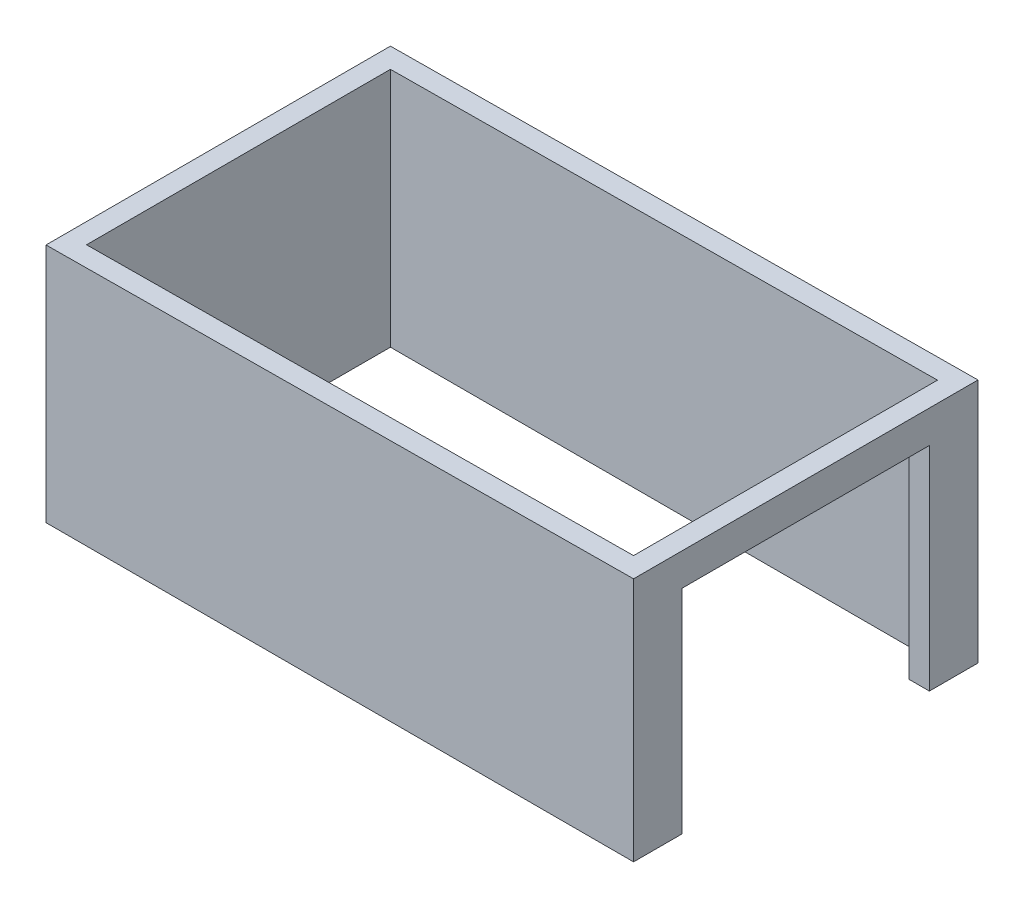
from build123d import *

# Parameters (mm, degrees)
SKETCH_1_W          = 5800
SKETCH_1_H          = 3400
SKETCH_1_W_2        = 5400
SKETCH_1_H_2        = 3000
EXTRUDE_1_DEPTH     = 2420
CUT_EXTRUDE_1_REACH = 5802
SKETCH_2_W          = 2440
SKETCH_2_H          = 2100
CUT_EXTRUDE_2_DEPTH = 3401


with BuildPart() as part:
    # Эскиз1 → Вытянуть-Тонкостенный1 (new body)
    with BuildSketch(Plane(origin=(0, 0, 0), x_dir=(1, 0, 0), z_dir=(0, 1, 0))):
        with Locations((2700, 1500)):
            Rectangle(SKETCH_1_W, SKETCH_1_H)
        with Locations((2700, 1500)):
            Rectangle(SKETCH_1_W_2, SKETCH_1_H_2, mode=Mode.SUBTRACT)
    extrude(amount=EXTRUDE_1_DEPTH)

    # Эскиз2 → Вырез-Вытянуть1 (cut, up to next)
    with BuildSketch(Plane(origin=(5600, 0, 0), x_dir=(0, 0, -1), z_dir=(1, 0, 0)), mode=Mode.PRIVATE) as cut_extrude_1_sk1:
        with Locations((1500, 1050)):
            Rectangle(SKETCH_2_W, SKETCH_2_H)
    cut_extrude_1_tool1 = extrude(cut_extrude_1_sk1.sketch, amount=-CUT_EXTRUDE_1_REACH, mode=Mode.PRIVATE) & part.part
    add(cut_extrude_1_tool1.solids().sort_by_distance((5600, 1050, -1500))[0], mode=Mode.SUBTRACT)

    # Эскиз3 → Вырез-Вытянуть2 (cut, through all)
    with BuildSketch(Plane(origin=(0, 0, -3200), x_dir=(-1, 0, 0), z_dir=(0, 0, -1))):
        Polygon((-5600, 2420), (200, 2420), (200, 2374), align=None)
    extrude(amount=-CUT_EXTRUDE_2_DEPTH, mode=Mode.SUBTRACT)


solid = part.part
